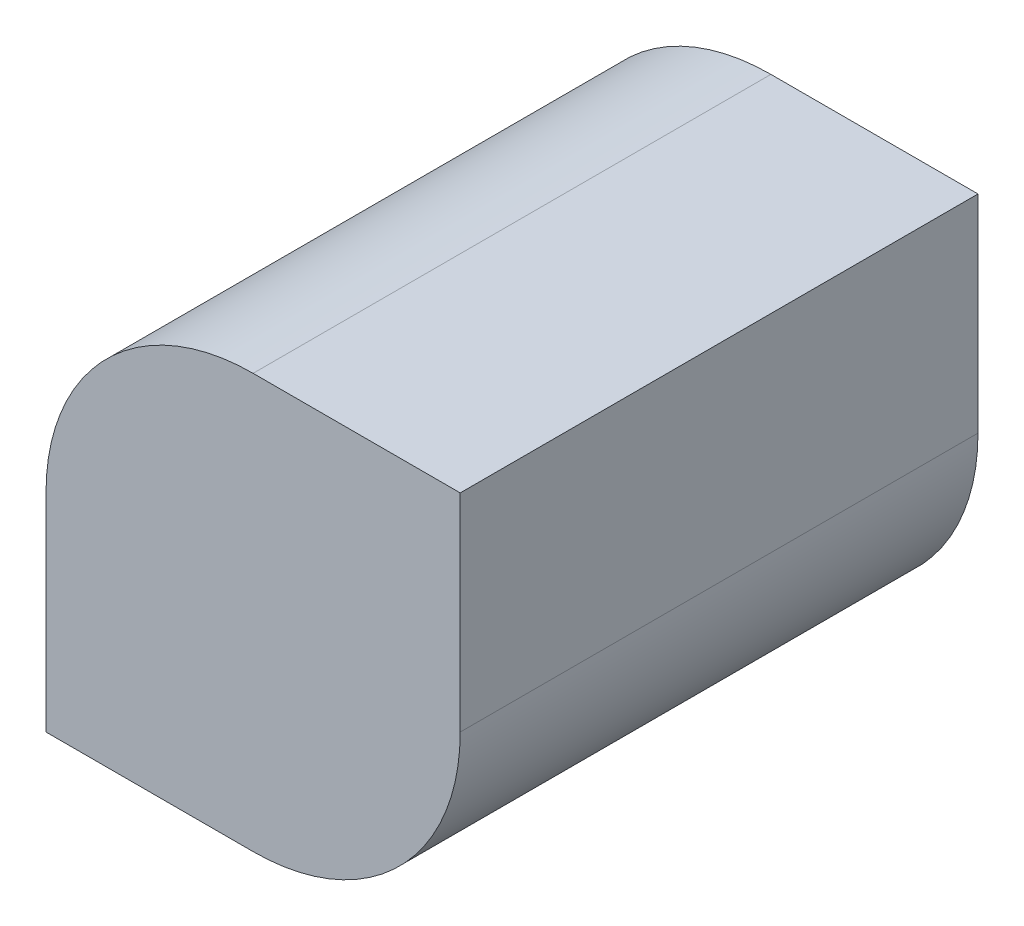
from build123d import *

# Parameters (mm, degrees)
BOSS_EXTRUDE1_DEPTH = 25


with BuildPart() as part:
    # Sketch1 → Boss-Extrude1 (new body)
    with BuildSketch(Plane.XY):
        with BuildLine():
            Line((-10, 0), (0, 0))
            ThreePointArc((0, 0), (7.071067812, 2.928932188), (10, 10))
            Line((10, 10), (10, 20))
            Line((10, 20), (0, 20))
            ThreePointArc((0, 20), (-7.071067812, 17.071067812), (-10, 10))
            Line((-10, 10), (-10, 0))
        make_face()
    extrude(amount=BOSS_EXTRUDE1_DEPTH)


solid = part.part
